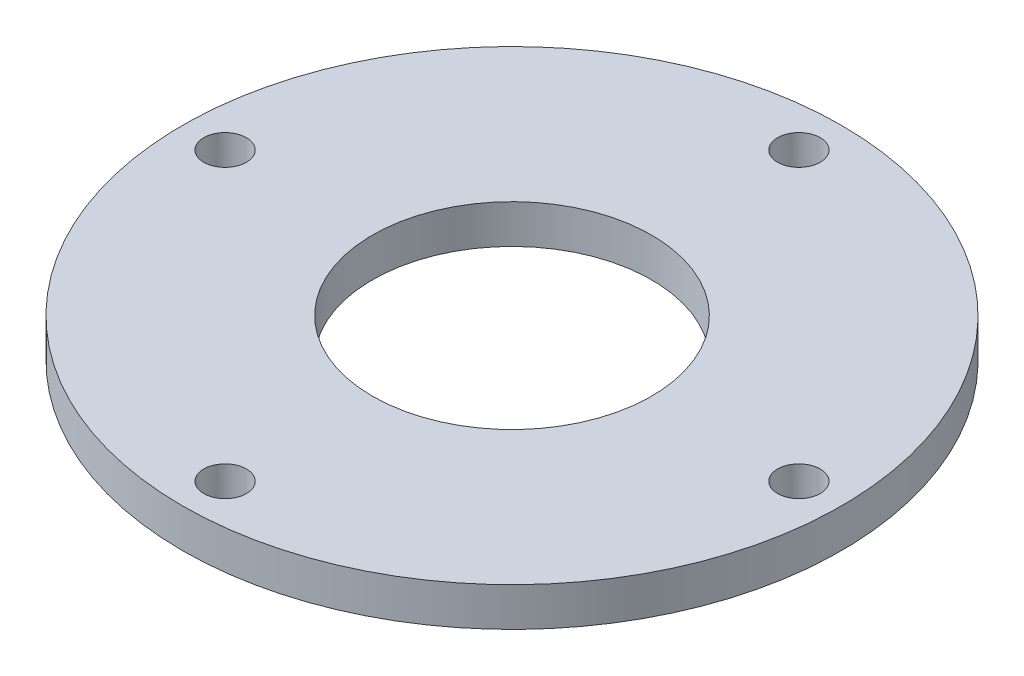
from build123d import *

# Parameters (mm, degrees)
M5_CLEARANCE_HOLE1_D = 5.5
CIRPATTERN1_COUNT    = 4


with BuildPart() as part:
    # Sketch1 → Revolve1 (revolve)
    with BuildSketch(Plane.XY):
        Polygon((-18, 2.5), (-42.5, 2.5), (-42.5, -2.5), (-31, -2.5), (-31, -5.5), (-26, -5.5), (-26, -2.5), (-18, -2.5), align=None)
    revolve(axis=Axis((0, 0, 0), (0, -1, 0)))

    # M5 Clearance Hole1 (through all)
    with Locations(Plane(origin=(37, 2.5, 0), x_dir=(0, 0, 1), z_dir=(0, 1, 0))):
        with Locations((0, 0)):
            m5_clearance_hole1 = Hole(M5_CLEARANCE_HOLE1_D / 2)

    # CirPattern1: M5 Clearance Hole1 ×4 about axis
    cirpattern1_axis = Axis((0, 55, 0), (0, -1, 0))
    for i in range(1, CIRPATTERN1_COUNT):
        add(m5_clearance_hole1.rotate(cirpattern1_axis, i * 360 / CIRPATTERN1_COUNT), mode=Mode.SUBTRACT)


solid = part.part
